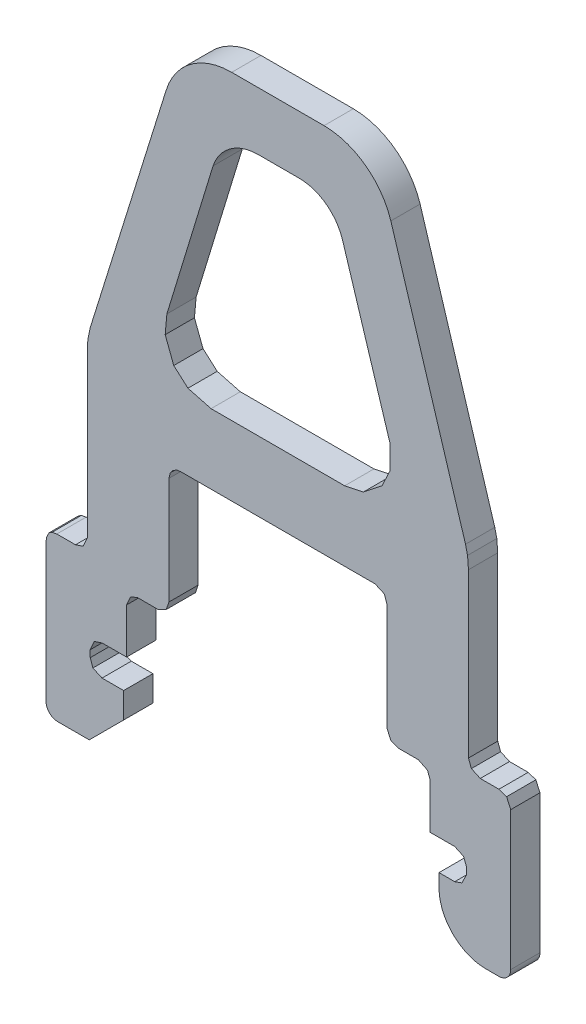
from build123d import *

# Parameters (mm, degrees)
EXTRUDE_1_DEPTH = 1.26


with BuildPart() as part:
    # Model → 凸台-拉伸1 (new body)
    with BuildSketch(Plane.XY):
        with BuildLine():
            Line((490.799011507, 297.269554061), (490.799011507, 293.800954061))
            Line((490.799011507, 293.800954061), (490.799011507, 292.024354061))
            Line((490.799011507, 292.024354061), (490.622317978, 291.628783411))
            Line((490.622317978, 291.628783411), (490.291411507, 291.516754061))
            Line((490.291411507, 291.516754061), (489.487672027, 291.516754061))
            Line((489.487672027, 291.516754061), (489.281948064, 291.476958221))
            Line((489.281948064, 291.476958221), (489.149260696, 291.389854061))
            Line((489.149260696, 291.389854061), (489.046979347, 291.176662061))
            Line((489.046979347, 291.176662061), (489.022411507, 291.009154061))
            Line((489.022411507, 291.009154061), (489.022411507, 285.044854061))
            ThreePointArc((489.022411507, 285.044854061), (489.156337447, 284.700557005), (489.487711507, 284.537254061))
            Line((489.487711507, 284.537254061), (490.883611507, 284.537254061))
            Line((490.883611507, 284.537254061), (492.364111507, 286.017754061))
            Line((492.364111507, 286.017754061), (492.364111507, 287.117554061))
            Line((492.364111507, 287.117554061), (491.433481153, 287.117554061))
            Line((491.433481153, 287.117554061), (491.037940858, 287.29424759))
            Line((491.037940858, 287.29424759), (490.925911507, 287.625154061))
            Line((490.925911507, 287.625154061), (490.925911507, 287.921254061))
            Line((490.925911507, 287.921254061), (491.102605037, 288.31682471))
            Line((491.102605037, 288.31682471), (491.433511507, 288.428854061))
            Line((491.433511507, 288.428854061), (492.491011507, 288.428854061))
            Line((492.491011507, 288.428854061), (492.491011507, 290.374654061))
            Line((492.491011507, 290.374654061), (492.66027648, 290.75646672))
            Line((492.66027648, 290.75646672), (492.956311507, 290.882254061))
            Line((492.956311507, 290.882254061), (493.84460586, 290.882254061))
            Line((493.84460586, 290.882254061), (494.20148544, 291.05894759))
            Line((494.20148544, 291.05894759), (494.309911507, 291.389854061))
            Line((494.309911507, 291.389854061), (494.309911507, 296.000554061))
            Line((494.309911507, 296.000554061), (494.374646074, 296.245014221))
            Line((494.374646074, 296.245014221), (494.479015049, 296.381254061))
            Line((494.479015049, 296.381254061), (494.65360679, 296.483586221))
            Line((494.65360679, 296.483586221), (494.817511507, 296.508154061))
            Line((494.817511507, 296.508154061), (503.192882713, 296.508154061))
            Line((503.192882713, 296.508154061), (503.588482157, 296.331460531))
            Line((503.588482157, 296.331460531), (503.700511507, 296.000554061))
            Line((503.700511507, 296.000554061), (503.700511507, 291.389854061))
            Line((503.700511507, 291.389854061), (503.877205037, 290.994283411))
            Line((503.877205037, 290.994283411), (504.208111507, 290.882254061))
            Line((504.208111507, 290.882254061), (505.054032978, 290.882254061))
            Line((505.054032978, 290.882254061), (505.449682157, 290.688050362))
            Line((505.449682157, 290.688050362), (505.561711507, 290.374654061))
            Line((505.561711507, 290.374654061), (505.561711507, 288.428854061))
            Line((505.561711507, 288.428854061), (506.619129356, 288.428854061))
            Line((506.619129356, 288.428854061), (507.001024166, 288.252160531))
            Line((507.001024166, 288.252160531), (507.126811507, 287.921254061))
            Line((507.126811507, 287.921254061), (507.126811507, 287.625154061))
            Line((507.126811507, 287.625154061), (506.932607808, 287.229583411))
            Line((506.932607808, 287.229583411), (506.619211507, 287.117554061))
            Line((506.619211507, 287.117554061), (505.942411507, 287.117554061))
            Line((505.942411507, 287.117554061), (505.942411507, 286.525354055))
            ThreePointArc((505.942411507, 286.525354055), (506.549193576, 285.114196381), (507.972811507, 284.537254055))
            Line((507.972811507, 284.537254055), (508.522711502, 284.537254055))
            ThreePointArc((508.522711502, 284.537254055), (508.881638908, 284.685926655), (509.030311507, 285.044854061))
            Line((509.030311507, 285.044854061), (509.030311507, 291.009154061))
            Line((509.030311507, 291.009154061), (508.853617978, 291.40472471))
            Line((508.853617978, 291.40472471), (508.522711507, 291.516754061))
            Line((508.522711507, 291.516754061), (507.718966182, 291.516754061))
            Line((507.718966182, 291.516754061), (507.337198848, 291.69344759))
            Line((507.337198848, 291.69344759), (507.211411507, 292.024354061))
            Line((507.211411507, 292.024354061), (507.211411507, 299.046154061))
            Line((507.211411507, 299.046154061), (507.171615667, 299.56111223))
            Line((507.171615667, 299.56111223), (507.084511507, 299.934454061))
            Line((507.084511507, 299.934454061), (503.869711507, 310.382554061))
            ThreePointArc((503.869711507, 310.382554061), (502.775635028, 311.908062049), (500.993311507, 312.497554061))
            Line((500.993311507, 312.497554061), (497.017111507, 312.497554061))
            ThreePointArc((497.017111507, 312.497554061), (495.247553689, 311.912414538), (494.183011507, 310.382554061))
            Line((494.183011507, 310.382554061), (490.925864157, 299.934454061))
            Line((490.925864157, 299.934454061), (490.823579347, 299.450764051))
            Line((490.823579347, 299.450764051), (490.799011507, 299.046154061))
            Line((490.799011507, 299.046154061), (490.799011507, 297.269554061))
        make_face()
        with BuildLine():
            Line((499.005211507, 310.001854061), (499.893511507, 310.001854061))
            ThreePointArc((499.893511507, 310.001854061), (501.078970997, 309.62259882), (501.797011507, 308.605954061))
            Line((501.797011507, 308.605954061), (503.827347931, 302.091754061))
            Line((503.827347931, 302.091754061), (503.840525184, 301.061837722))
            Line((503.840525184, 301.061837722), (503.4889366, 300.315154061))
            Line((503.4889366, 300.315154061), (502.680170534, 299.676222374))
            Line((502.680170534, 299.676222374), (501.881611507, 299.511454061))
            Line((501.881611507, 299.511454061), (499.005211507, 299.511454061))
            Line((499.005211507, 299.511454061), (496.12871426, 299.511454061))
            Line((496.12871426, 299.511454061), (495.132361574, 299.775167827))
            Line((495.132361574, 299.775167827), (494.521372494, 300.315154061))
            Line((494.521372494, 300.315154061), (494.15297783, 301.28253408))
            Line((494.15297783, 301.28253408), (494.225311507, 302.091754061))
            Line((494.225311507, 302.091754061), (496.213411507, 308.605954061))
            ThreePointArc((496.213411507, 308.605954061), (496.961295967, 309.617562087), (498.159211507, 310.001854061))
            Line((498.159211507, 310.001854061), (499.005211507, 310.001854061))
        make_face(mode=Mode.SUBTRACT)
    extrude(amount=EXTRUDE_1_DEPTH)


solid = part.part
